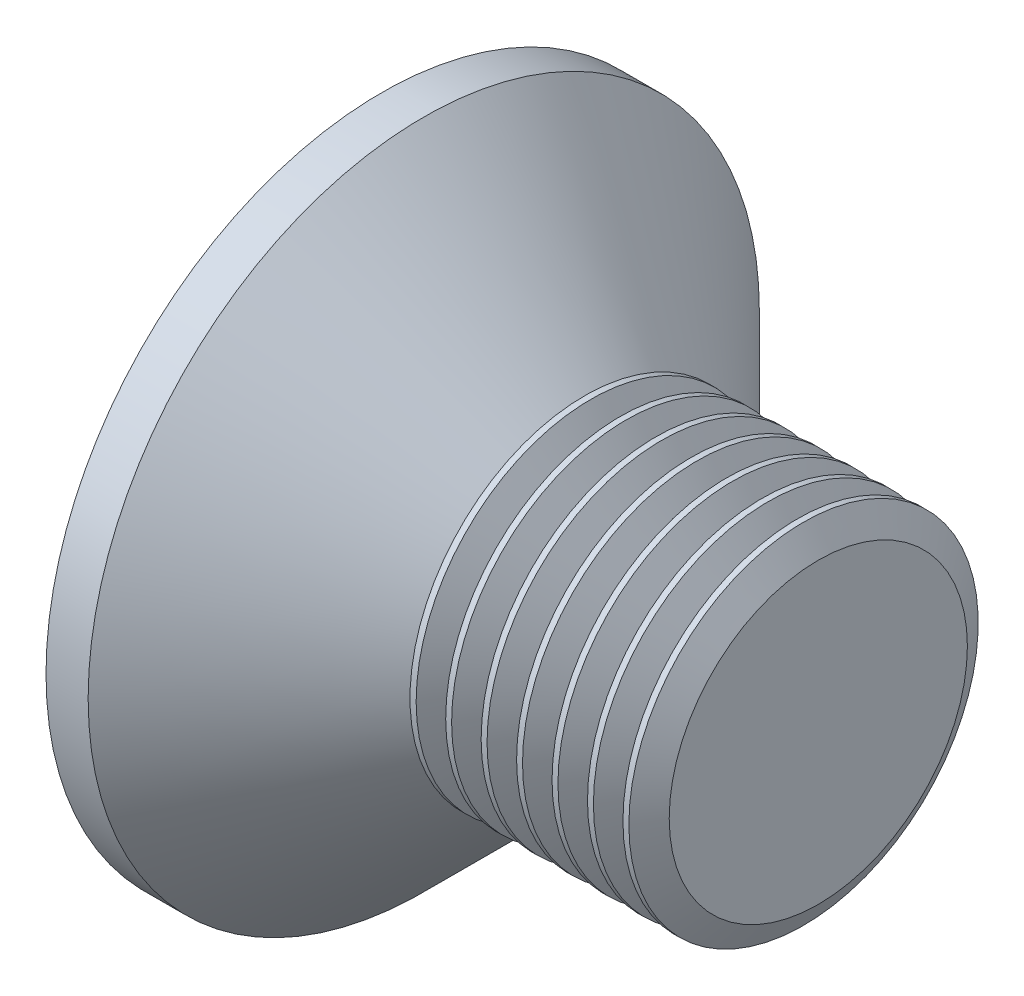
from build123d import *

# Parameters (mm, degrees)
CROSSRECESS_DEPTH = 2.325
DRAFT9_ANGLE      = 30
FILLET5_R         = 0.3
LPATTERN10_COUNT  = 7
LPATTERN10_PITCH  = 0.8118


with BuildPart() as part:
    # Sketch1 → Base (revolve)
    with BuildSketch(Plane.XY):
        Polygon((10, 4), (7.15, 4), (4.65, 4), (0.965, 7.685), (0, 7.685), (0, 0), (10, 0), align=None)
    revolve(axis=Axis((4.515812911, 0, 0), (-1, 0, 0)))

    # Sketch6 → CrossRecess (cut)
    with BuildSketch(Plane(origin=(0, 0, 0), x_dir=(0, 0, -1), z_dir=(1, 0, 0))):
        Polygon((0.89, 0.89), (0.89, 4.45), (-0.89, 4.45), (-0.89, 0.89), (-4.45, 0.89), (-4.45, -0.89), (-0.89, -0.89), (-0.89, -4.45), (0.89, -4.45), (0.89, -0.89), (4.45, -0.89), (4.45, 0.89), align=None)
    extrude(amount=CROSSRECESS_DEPTH, mode=Mode.SUBTRACT)

    # Draft9
    draft9_faces = [part.faces().sort_by_distance(p)[0] for p in [
        (1.1625, 4.45, 0),
        (1.1625, 0, 4.45),
        (1.1625, -4.45, 0),
        (1.1625, 0, -4.45),
    ]]
    draft(draft9_faces, Plane(origin=(0, 7.685, 0), x_dir=(0, 0, -1), z_dir=(-1, 0, 0)), DRAFT9_ANGLE)

    # Fillet5
    fillet5_edges = [part.edges().sort_by_distance(p)[0] for p in [
        (1.1625, 0.89, 0.89),
        (1.1625, -0.89, 0.89),
        (1.1625, -0.89, -0.89),
        (1.1625, 0.89, -0.89),
    ]]
    fillet(fillet5_edges, radius=FILLET5_R)

    # Sketch9 → Cut-Revolve10 (revolve, cut)
    with BuildSketch(Plane.XY):
        Polygon((10, 3.414133814), (10.33825, 4), (10.33825, 4.6765), (9.66175, 4.6765), (9.66175, 4), align=None)
    cut_revolve10 = revolve(axis=Axis((0, 0, 0), (1, 0, 0)), mode=Mode.SUBTRACT)

    # LPattern10: Cut-Revolve10 ×7
    with Locations(*[(-i * LPATTERN10_PITCH, 0, 0) for i in range(1, LPATTERN10_COUNT)]):
        add(cut_revolve10, mode=Mode.SUBTRACT)


solid = part.part
